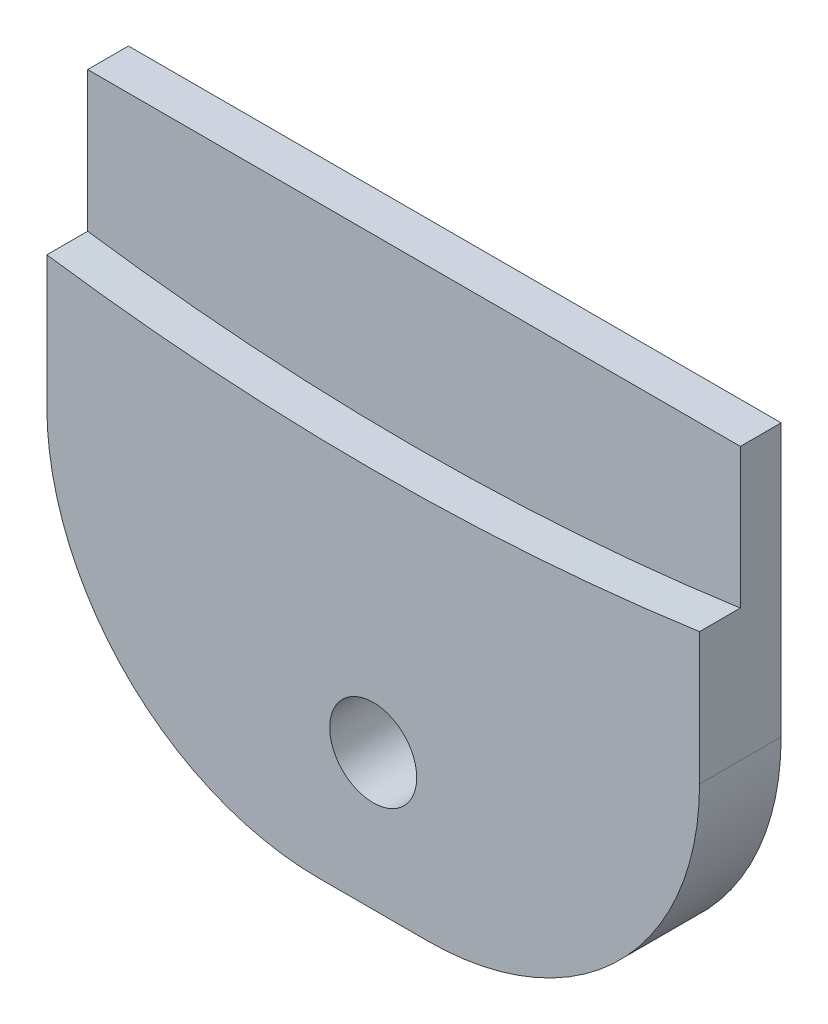
from build123d import *

# Parameters (mm, degrees)
SKETCH1_W           = 24
SKETCH1_H           = 20
BOSS_EXTRUDE1_DEPTH = 3
SKETCH3_R           = 1.6
CUT_EXTRUDE1_DEPTH  = 4
CUT_EXTRUDE2_DEPTH  = 1.5
FILLET1_R           = 10


with BuildPart() as part:
    # Sketch1 → Boss-Extrude1 (new body)
    with BuildSketch(Plane.XY):
        with Locations((0, 10)):
            Rectangle(SKETCH1_W, SKETCH1_H)
    extrude(amount=BOSS_EXTRUDE1_DEPTH)

    # Sketch3 → Cut-Extrude1 (cut, through all)
    with BuildSketch(Plane.XY.offset(3)):
        with Locations((0, 5)):
            Circle(SKETCH3_R)
    extrude(amount=-CUT_EXTRUDE1_DEPTH, mode=Mode.SUBTRACT)

    # Sketch2 → Cut-Extrude2 (cut)
    with BuildSketch(Plane.XY.offset(3)):
        with BuildLine():
            Line((-12, 14.851322054), (-12, 20))
            Line((-12, 20), (12, 20))
            Line((12, 20), (12, 14.851322054))
            ThreePointArc((12, 14.851322054), (0, 14), (-12, 14.851322054))
        make_face()
    extrude(amount=-CUT_EXTRUDE2_DEPTH, mode=Mode.SUBTRACT)

    # Fillet1
    fillet1_edges = [part.edges().sort_by_distance(p)[0] for p in [
        (12, 0, 1.5),
        (-12, 0, 1.5),
    ]]
    fillet(fillet1_edges, radius=FILLET1_R)


solid = part.part
